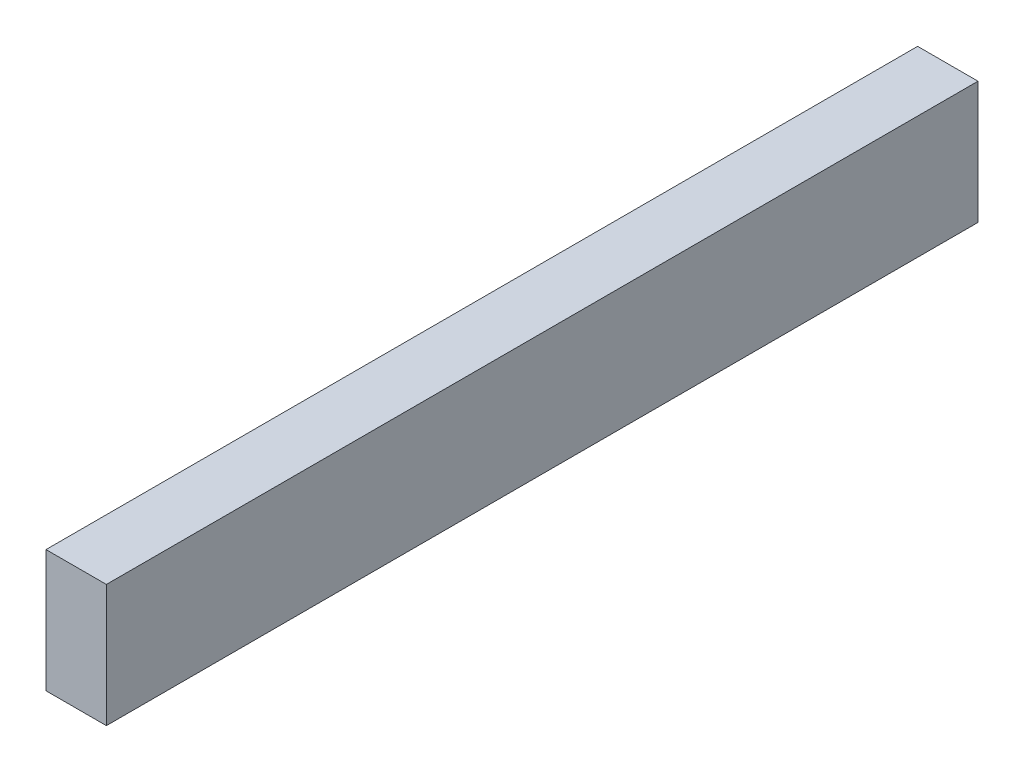
from build123d import *

# Parameters (mm, degrees)
SKETCH1_W           = 20.78085257
SKETCH1_H           = 42.099140982
BOSS_EXTRUDE1_DEPTH = 300


with BuildPart() as part:
    # Sketch1 → Boss-Extrude1 (new body)
    with BuildSketch(Plane.XY):
        Rectangle(SKETCH1_W, SKETCH1_H)
    extrude(amount=BOSS_EXTRUDE1_DEPTH)


solid = part.part
